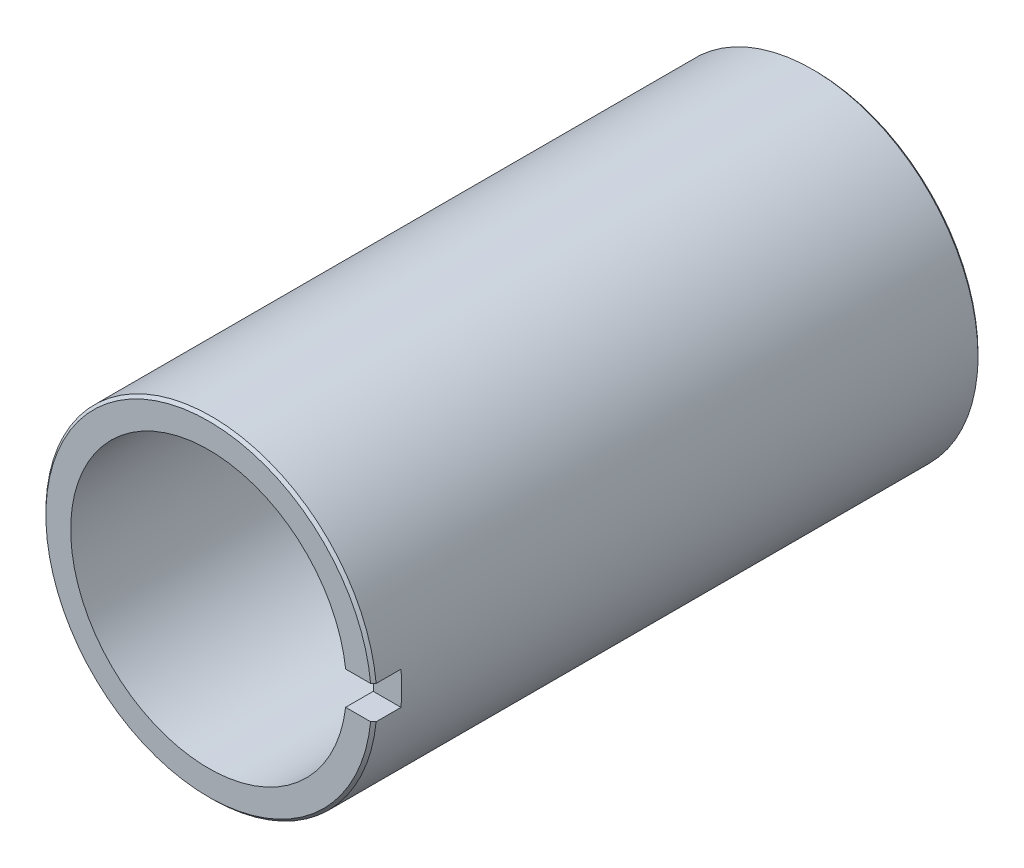
from build123d import *

# Parameters (mm, degrees)
SKETCH1_R           = 30
SKETCH1_R_2         = 25
BOSS_EXTRUDE1_DEPTH = 109.9
SKETCH2_W           = 5
SKETCH2_H           = 6
CUT_EXTRUDE1_DEPTH  = 31
CHAMFER1_SIZE       = 0.5


with BuildPart() as part:
    # Sketch1 → Boss-Extrude1 (new body)
    with BuildSketch(Plane.XY):
        Circle(SKETCH1_R)
        Circle(SKETCH1_R_2, mode=Mode.SUBTRACT)
    extrude(amount=BOSS_EXTRUDE1_DEPTH)

    # Sketch2 → Cut-Extrude1 (cut, through all)
    with BuildSketch(Plane(origin=(0, 0, 0), x_dir=(0, 0, -1), z_dir=(1, 0, 0))):
        with Locations((-107.4, 0)):
            Rectangle(SKETCH2_W, SKETCH2_H)
    extrude(amount=CUT_EXTRUDE1_DEPTH, mode=Mode.SUBTRACT)

    # Chamfer1
    chamfer1_edges = [part.edges().sort_by_distance(p)[0] for p in [
        (-30, 0, 109.9),
        (-30, 0, 0),
    ]]
    chamfer(chamfer1_edges, length=CHAMFER1_SIZE)


solid = part.part
